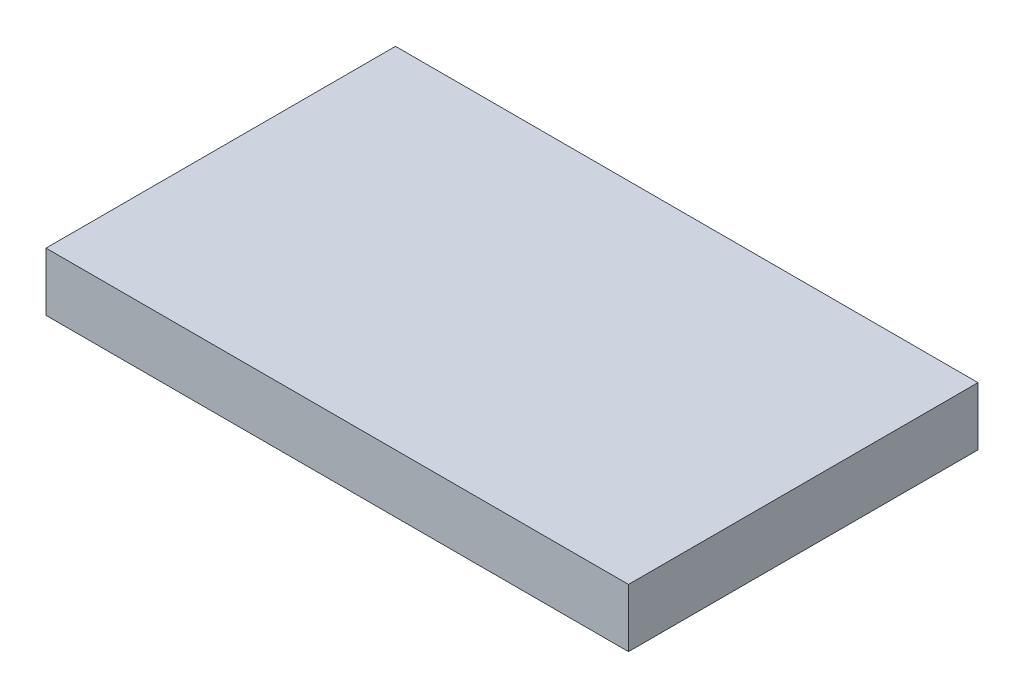
from build123d import *

# Parameters (mm, degrees)
SKETCH1_W           = 100
SKETCH1_H           = 60
BOSS_EXTRUDE1_DEPTH = 10


with BuildPart() as part:
    # Sketch1 → Boss-Extrude1 (new body)
    with BuildSketch(Plane(origin=(0, 0, 0), x_dir=(1, 0, 0), z_dir=(0, 1, 0))):
        Rectangle(SKETCH1_W, SKETCH1_H)
    extrude(amount=BOSS_EXTRUDE1_DEPTH)


solid = part.part
